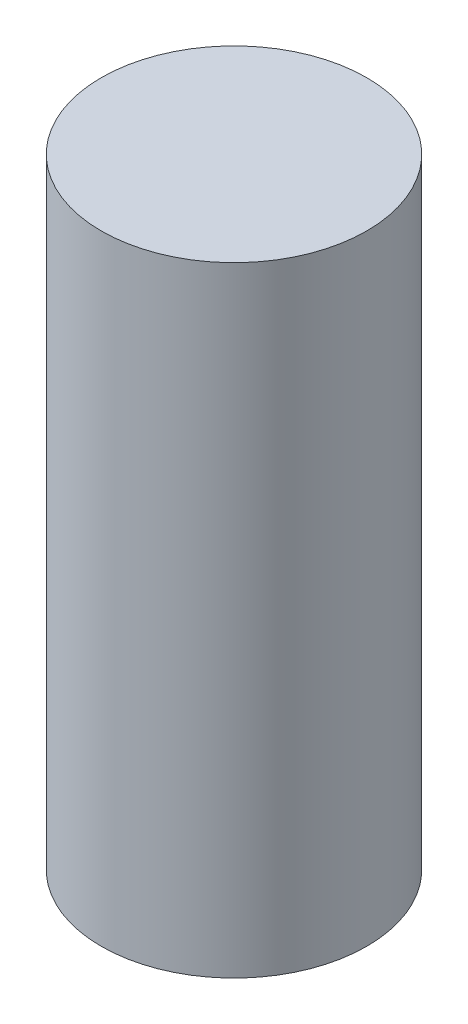
from build123d import *


with BuildPart() as part:
    # Sketch1 → Revolve1 (revolve)
    with BuildSketch(Plane.XY):
        Polygon((0, 0), (0.762, 0), (0.762, 8.89), (-1.143, 8.89), (-1.143, 5.08), (0, 5.08), align=None)
    revolve(axis=Axis((-1.143, 0.150539844, 0), (0, 1, 0)))


solid = part.part
